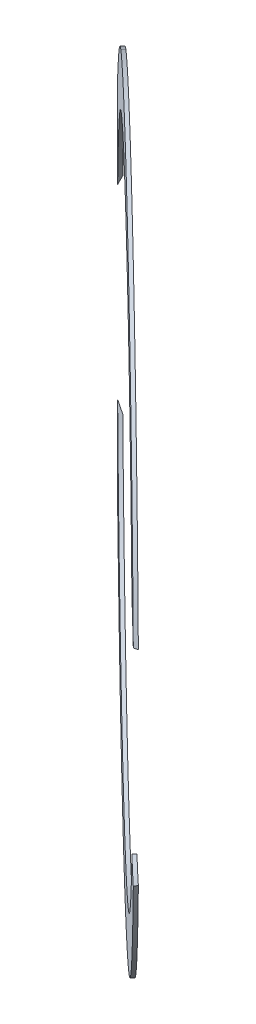
from build123d import *

# Parameters (mm, degrees)
SKETCH2_R               = 298.47899177
SKETCH2_R_2             = 257.20399177
EXTRUDE1_DEPTH          = 3.2258
SKETCH3_R               = 101.6
CUT_EXTRUDE1_DEPTH      = 613.784324244
SKETCH4_R               = 381
CUT_EXTRUDE2_DEPTH      = 2.032
CUT_EXTRUDE2_DEPTH_BACK = 607.43442205
CUT_EXTRUDE3_DEPTH      = 413.89718972


with BuildPart() as part:
    # Sketch2 → Extrude1 (new body)
    with BuildSketch(Plane(origin=(-164.227634794, 0, 170.588907734), x_dir=(0.7204112876391361, 0, 0.6935470976380206), z_dir=(-0.6935470976380206, 0, 0.7204112876391361))):
        Circle(SKETCH2_R)
        Circle(SKETCH2_R_2, mode=Mode.SUBTRACT)
    extrude(amount=-EXTRUDE1_DEPTH)

    # Sketch3 → Cut-Extrude1 (cut, through all)
    with BuildSketch(Plane.XY):
        Circle(SKETCH3_R)
    extrude(amount=CUT_EXTRUDE1_DEPTH, mode=Mode.SUBTRACT)

    # Sketch4 → Cut-Extrude2 (cut, two sides)
    with BuildSketch(Plane.XY) as cut_extrude2_sk:
        Circle(SKETCH4_R)
    extrude(amount=CUT_EXTRUDE2_DEPTH, mode=Mode.SUBTRACT)
    extrude(cut_extrude2_sk.sketch, amount=-CUT_EXTRUDE2_DEPTH_BACK, mode=Mode.SUBTRACT)


with BuildPart() as cut_extrude2_piece_1:
    # of the separate pieces the step leaves, piece 1, a body of its own (cut_extrude2_pieces)
    add(part.part.solids().sort_by_distance((-339.313507628, -173.272082337, 2.032))[0])


with BuildPart() as cut_extrude2_piece_2:
    # of the separate pieces the step leaves, piece 2, a body of its own (cut_extrude2_pieces)
    add(part.part.solids().sort_by_distance((-334.662345492, 177.878308285, 2.032))[0])


with BuildPart() as cut_revolve5_tool:
    # Sketch5 → Cut-Revolve5 (revolve)
    with BuildSketch(Plane(origin=(0, 0, 0), x_dir=(1, 0, 0), z_dir=(0, 1, 0))):
        with BuildLine():
            Line((-373.3022368, -76.2), (-525.7022368, -76.2))
            Line((-525.7022368, -76.2), (-525.7022368, 76.2))
            Line((-525.7022368, 76.2), (-373.3022368, 76.2))
            add(Edge.make_bspline(
                [(-373.3022368, 76.2), (-388.856496667, 0), (-373.3022368, -76.2)],
                knots=[3.751711748, 3.751711748, 3.751711748, 5.673066213, 5.673066213, 5.673066213], degree=2, weights=[1, 0.572965072, 1]))
        make_face()
    revolve(axis=Axis((0, 0, 0), (0, 0, 1)))


with BuildPart() as cut_extrude2_piece_1_1:
    add(cut_extrude2_piece_1.part)

    # Cut-Revolve5: cut by cut_revolve5_tool
    add(cut_revolve5_tool.part, mode=Mode.SUBTRACT)


with BuildPart() as cut_extrude2_piece_2_1:
    add(cut_extrude2_piece_2.part)

    # Cut-Revolve5: cut by cut_revolve5_tool
    add(cut_revolve5_tool.part, mode=Mode.SUBTRACT)


with BuildPart() as cut_extrude3_tool:
    # Sketch6 → Cut-Extrude3 (new, through all)
    with BuildSketch(Plane(origin=(-164.227634794, 0, 170.588907734), x_dir=(0.720411287639136, 0, 0.6935470976380206), z_dir=(-0.6935470976380206, 0, 0.720411287639136))):
        with BuildLine():
            Line((-243.035993241, 168.7622191), (-243.035993241, 265.645662397))
            Line((-243.035993241, 265.645662397), (-136.095887439, 265.645662397))
            add(Edge.make_bspline(
                [(-243.035993241, 168.7622191), (-236.073192799, 178.81372708), (-228.600124987, 188.365480079), (-212.699682128, 206.534339224), (-204.272986727, 215.152111012), (-190.918840798, 227.37937762), (-186.347935418, 231.338072142), (-176.957107882, 239.011574584), (-172.137535558, 242.72672513), (-162.22593818, 249.89018649), (-157.168166325, 253.315093679), (-149.411750774, 258.173655162), (-146.797416665, 259.746699718), (-141.501528842, 262.784547331), (-138.820306945, 264.249884702), (-136.095887439, 265.645662397)],
                knots=[0, 0, 0, 0, 0.25, 0.25, 0.5, 0.5, 0.625, 0.625, 0.75, 0.75, 0.875, 0.875, 0.9375, 0.9375, 1, 1, 1, 1], degree=3))
        make_face()
        with BuildLine():
            Line((-243.035993241, -168.7622191), (-243.035993241, -265.645662397))
            Line((-243.035993241, -265.645662397), (-136.095887439, -265.645662397))
            add(Edge.make_bspline(
                [(-136.095887439, -265.645662397), (-138.81358705, -264.253327446), (-141.490093076, -262.790832153), (-146.779385996, -259.757316018), (-149.391862349, -258.185766269), (-154.561405307, -254.948293654), (-157.121073222, -253.280304755), (-162.170048063, -249.871314446), (-164.660725074, -248.129506053), (-172.038584185, -242.80015254), (-176.832048478, -239.109180253), (-186.188456762, -231.472832985), (-190.751100547, -227.527126699), (-204.102969746, -215.319128934), (-212.558128719, -206.688161028), (-222.558047173, -195.271468149), (-224.52939951, -192.956531952), (-228.413886115, -188.262409971), (-230.325108237, -185.885421736), (-235.951043458, -178.681435362), (-239.563736335, -173.774773789), (-243.035993241, -168.7622191)],
                knots=[0, 0, 0, 0, 0.0625, 0.0625, 0.125, 0.125, 0.1875, 0.1875, 0.25, 0.25, 0.375, 0.375, 0.5, 0.5, 0.75, 0.75, 0.8125, 0.8125, 0.875, 0.875, 1, 1, 1, 1], degree=3))
        make_face()
    extrude(amount=-CUT_EXTRUDE3_DEPTH)


with BuildPart() as cut_extrude2_piece_1_2:
    add(cut_extrude2_piece_1_1.part)

    # Cut-Extrude3: cut by cut_extrude3_tool
    add(cut_extrude3_tool.part, mode=Mode.SUBTRACT)


with BuildPart() as cut_extrude2_piece_2_2:
    add(cut_extrude2_piece_2_1.part)

    # Cut-Extrude3: cut by cut_extrude3_tool
    add(cut_extrude3_tool.part, mode=Mode.SUBTRACT)


solid = Compound([cut_extrude2_piece_1_2.part, cut_extrude2_piece_2_2.part])
